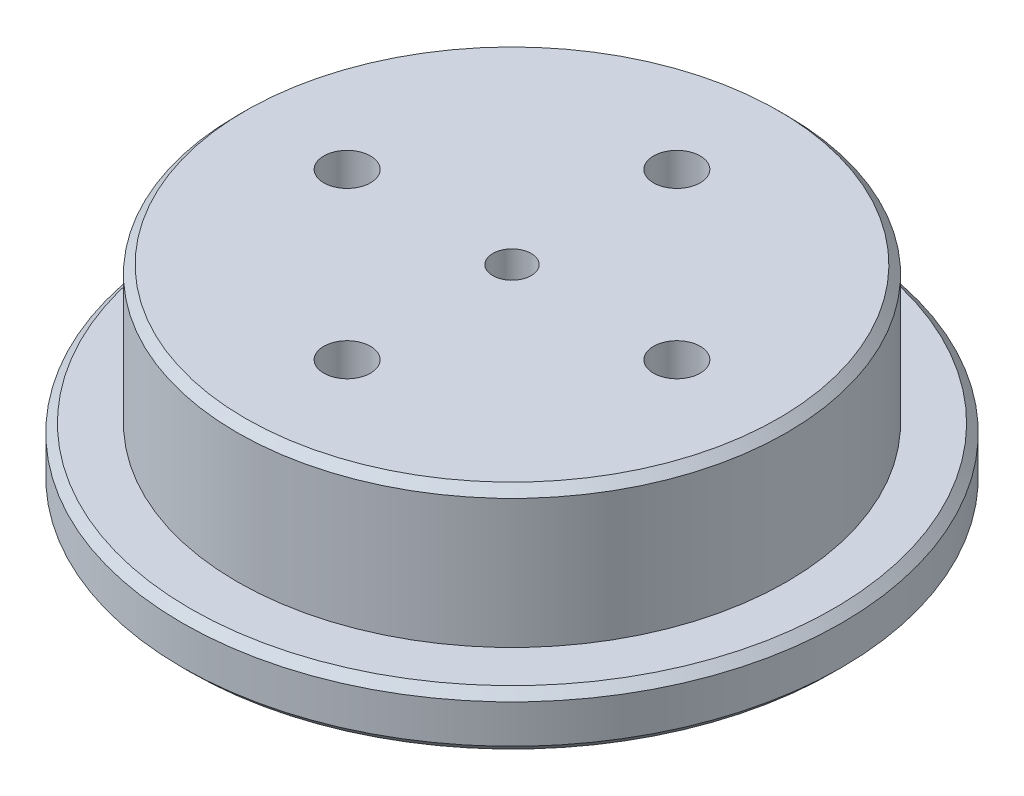
from build123d import *

# Parameters (mm, degrees)
SKETCH_1_R             = 120
EXTRUDE_1_DEPTH        = 20
SKETCH_2_R             = 100
EXTRUDE_2_DEPTH        = 50
SKETCH_3_R             = 8.5
CUT_EXTRUDE_1_DEPTH    = 80
SKETCH_4_R             = 20
EXTRUDE_3_DEPTH        = 20
HOLE_WIZARD_M161_D     = 14
HOLE_WIZARD_M161_DEPTH = 20
HOLE_WIZARD_M161_TIP   = 4.206024333
CHAMFER_1_SIZE         = 3
CHAMFER_2_SIZE         = 3


with BuildPart() as part:
    # Эскиз1 → Бобышка-Вытянуть1 (new body)
    with BuildSketch(Plane(origin=(0, 0, 0), x_dir=(1, 0, 0), z_dir=(0, 1, 0))):
        Circle(SKETCH_1_R)
    extrude(amount=EXTRUDE_1_DEPTH)

    # Эскиз2 → Бобышка-Вытянуть2 (add)
    with BuildSketch(Plane(origin=(0, 20, 0), x_dir=(1, 0, 0), z_dir=(0, 1, 0))):
        Circle(SKETCH_2_R)
    extrude(amount=EXTRUDE_2_DEPTH)

    # Эскиз3 → Вырез-Вытянуть1 (cut)
    with BuildSketch(Plane(origin=(0, 70, 0), x_dir=(1, 0, 0), z_dir=(0, 1, 0))):
        with Locations((0, 60)):
            Circle(SKETCH_3_R)
        with Locations((60, 0)):
            Circle(SKETCH_3_R)
        with Locations((0, -60)):
            Circle(SKETCH_3_R)
        with Locations((-60, 0)):
            Circle(SKETCH_3_R)
    extrude(amount=-CUT_EXTRUDE_1_DEPTH, mode=Mode.SUBTRACT)

    # Эскиз4 → Бобышка-Вытянуть3 (add)
    with BuildSketch(Plane.XZ):
        Circle(SKETCH_4_R)
    extrude(amount=EXTRUDE_3_DEPTH)

    # Отверстие обработанное метчиком M161
    with Locations(Plane(origin=(0, 70, 0), x_dir=(1, 0, 0), z_dir=(0, 1, 0))):
        with Locations((0, 0)):
            Hole(HOLE_WIZARD_M161_D / 2, depth=HOLE_WIZARD_M161_DEPTH)
            with Locations((0, 0, -(HOLE_WIZARD_M161_DEPTH + HOLE_WIZARD_M161_TIP / 2))):  # 118° drill point
                Cone(0, HOLE_WIZARD_M161_D / 2, HOLE_WIZARD_M161_TIP, mode=Mode.SUBTRACT)

    # Фаска1
    chamfer_1_edges = [part.edges().sort_by_distance(p)[0] for p in [
        (-120, 0, 0),
        (-120, 20, 0),
        (-100, 70, 0),
    ]]
    chamfer(chamfer_1_edges, length=CHAMFER_1_SIZE)

    # Фаска2
    chamfer_2_edges = [part.edges().sort_by_distance(p)[0] for p in [
        (-20, -20, 0),
    ]]
    chamfer(chamfer_2_edges, length=CHAMFER_2_SIZE)


solid = part.part
